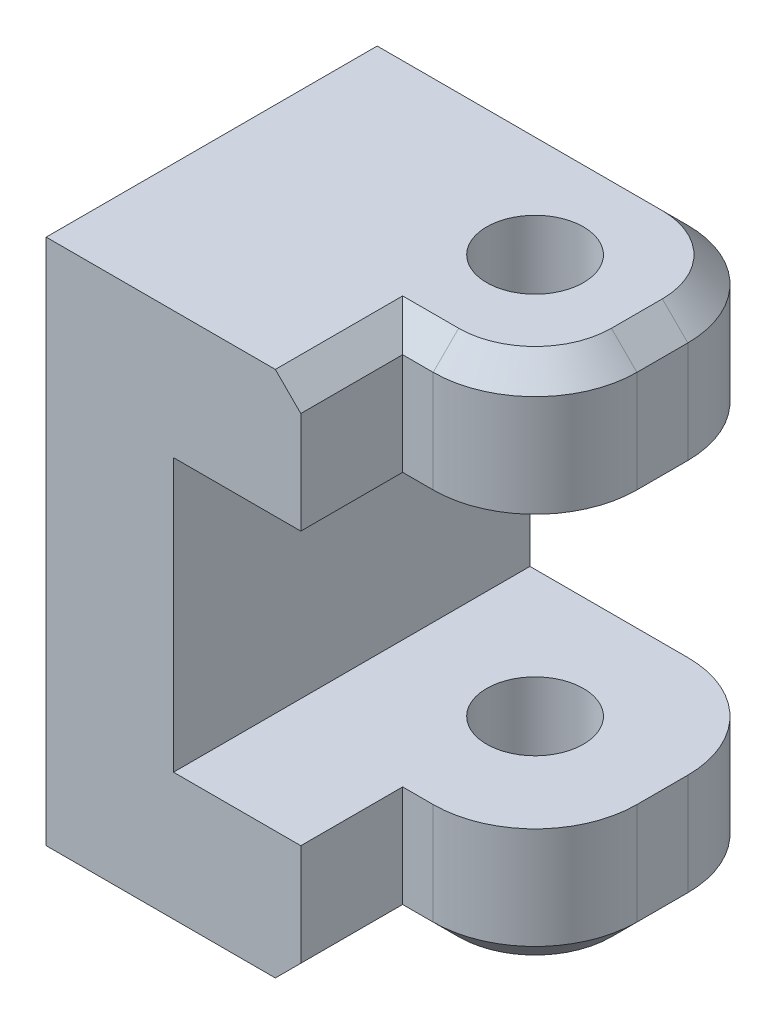
from build123d import *

# Parameters (mm, degrees)
SKETCH_1_R               = 6.25
EXTRUDE_1_DEPTH          = 15
SKETCH_2_W               = 29.5
SKETCH_2_H               = 20.7
EXTRUDE_2_DEPTH          = 5
SKETCH_3_W               = 39
SKETCH_3_H               = 20.7
SKETCH_3_R               = 1.6
EXTRUDE_3_DEPTH          = 5
SKETCH_4_W               = 10
SKETCH_4_H               = 5
EXTRUDE_4_DEPTH          = 10.2
SKETCH_5_R               = 1.9
CUT_EXTRUDE_1_DEPTH      = 21.7
FILLET_1_R               = 4
SKETCH_8_W               = 24
SKETCH_8_H               = 5
EXTRUDE_6_DEPTH          = 5
SKETCH_9_R               = 1.6
EXTRUDE_7_DEPTH          = 5
EXTRUDE_5_DEPTH          = 3
CHAMFER_1_SIZE           = 1
CHAMFER_2_SIZE           = 1
SKETCH_10_W              = 6.3
SKETCH_10_H              = 5.8
CUT_EXTRUDE_2_DEPTH      = 2.5
SKETCH_11_R              = 1.65
CUT_EXTRUDE_3_DEPTH      = 25.95
CUT_EXTRUDE_3_DEPTH_BACK = 15.75
CUT_EXTRUDE_4_DEPTH      = 1
CUT_EXTRUDE_4_DEPTH_BACK = 21.7


with BuildPart() as part:
    # ｽｹｯﾁ1 → ﾎﾞｽ - 押し出し1 (new body)
    with BuildSketch(Plane.XY):
        Circle(SKETCH_1_R)
    extrude(amount=-EXTRUDE_1_DEPTH)

    # ｽｹｯﾁ2 → ﾎﾞｽ - 押し出し2 (add)
    with BuildSketch(Plane.XY):
        Rectangle(SKETCH_2_W, SKETCH_2_H)
    extrude(amount=EXTRUDE_2_DEPTH)

    # ｽｹｯﾁ3 → ﾎﾞｽ - 押し出し3 (add)
    with BuildSketch(Plane(origin=(14.75, 0, 0), x_dir=(0, 0, -1), z_dir=(1, 0, 0))):
        with Locations((-24.5, 0)):
            Rectangle(SKETCH_3_W, SKETCH_3_H)
        with Locations((-20, 0)):
            Circle(SKETCH_3_R, mode=Mode.SUBTRACT)
    extrude(amount=-EXTRUDE_3_DEPTH)

    # ｽｹｯﾁ4 → ﾎﾞｽ - 押し出し4 (add)
    with BuildSketch(Plane(origin=(14.75, 0, 0), x_dir=(0, 0, -1), z_dir=(1, 0, 0))):
        with Locations((-5, 7.85)):
            Rectangle(SKETCH_4_W, SKETCH_4_H)
        with Locations((-5, -7.85)):
            Rectangle(SKETCH_4_W, SKETCH_4_H)
        with Locations((-39, 7.85)):
            Rectangle(SKETCH_4_W, SKETCH_4_H)
        with Locations((-39, -7.85)):
            Rectangle(SKETCH_4_W, SKETCH_4_H)
    extrude(amount=EXTRUDE_4_DEPTH)

    # ｽｹｯﾁ5 → ｶｯﾄ - 押し出し1 (cut, through all)
    with BuildSketch(Plane.XZ.offset(10.35)):
        with Locations((19.95, 5)):
            Circle(SKETCH_5_R)
        with Locations((19.95, 39)):
            Circle(SKETCH_5_R)
    extrude(amount=-CUT_EXTRUDE_1_DEPTH, mode=Mode.SUBTRACT)

    # ﾌｨﾚｯﾄ1
    fillet_1_edges = [part.edges().sort_by_distance(p)[0] for p in [
        (24.95, 7.85, 0),
        (24.95, 7.85, 10),
        (24.95, -7.85, 0),
        (24.95, -7.85, 10),
        (24.95, -7.85, 44),
        (24.95, -7.85, 34),
        (24.95, 7.85, 44),
        (24.95, 7.85, 34),
    ]]
    fillet(fillet_1_edges, radius=FILLET_1_R)

    # ｽｹｯﾁ8 → ﾎﾞｽ - 押し出し6 (add)
    with BuildSketch(Plane(origin=(14.75, 0, 0), x_dir=(0, 0, -1), z_dir=(1, 0, 0))):
        with Locations((-22, 7.85)):
            Rectangle(SKETCH_8_W, SKETCH_8_H)
        with Locations((-22, -7.85)):
            Rectangle(SKETCH_8_W, SKETCH_8_H)
    extrude(amount=EXTRUDE_6_DEPTH)

    # ｽｹｯﾁ9 → ﾎﾞｽ - 押し出し7 (add)
    with BuildSketch(Plane.ZY.offset(14.75)):
        with BuildLine():
            Line((5, 10.35), (11, 10.35))
            Line((11, 10.35), (22.121751649, 3.390895153))
            ThreePointArc((22.121751649, 3.390895153), (24, 0), (22.121751649, -3.390895153))
            Line((22.121751649, -3.390895153), (11, -10.35))
            Line((11, -10.35), (5, -10.35))
            Line((5, -10.35), (5, 10.35))
        make_face()
        with Locations((20, 0)):
            Circle(SKETCH_9_R, mode=Mode.SUBTRACT)
    extrude(amount=-EXTRUDE_7_DEPTH)

    # ｽｹｯﾁ6 → ﾎﾞｽ - 押し出し5 (add)
    with BuildSketch(Plane.XZ.offset(10.35)):
        Polygon((-9.75, 5), (9.75, 5), (9.75, 15), (-2.374355653, 8), (-9.75, 8), align=None)
    extrude_5 = extrude(amount=-EXTRUDE_5_DEPTH)

    # ﾐﾗｰ1: ﾎﾞｽ - 押し出し5 across plane
    add(extrude_5.mirror(Plane.ZX))

    # 面取り1
    chamfer_1_edges = [part.edges().sort_by_distance(p)[0] for p in [
        (20.35, -10.35, 34),
        (24.95, -10.35, 5),
        (20.35, -10.35, 10),
        (23.778427125, -10.35, 8.828427125),
        (23.778427125, -10.35, 1.171572875),
        (23.778427125, -10.35, 42.828427125),
        (23.778427125, -10.35, 35.171572875),
        (24.95, 10.35, 39),
        (3.1, 10.35, 0),
        (20.35, 10.35, 34),
        (20.35, 10.35, 10),
        (24.95, 10.35, 5),
        (23.778427125, 10.35, 1.171572875),
        (23.778427125, 10.35, 8.828427125),
        (23.778427125, 10.35, 42.828427125),
        (23.778427125, 10.35, 35.171572875),
        (19.75, 10.35, 22),
        (19.75, -10.35, 22),
        (9.75, -10.35, 29.5),
        (9.75, 0, 44),
        (15.35, -10.35, 44),
        (15.35, 10.35, 44),
        (9.75, 10.35, 29.5),
        (-14.75, 0, 0),
        (-14.75, 10.35, 5.5),
        (3.1, -10.35, 0),
        (-14.75, -10.35, 5.5),
        (24.95, -10.35, 39),
    ]]
    chamfer(chamfer_1_edges, length=CHAMFER_1_SIZE)

    # 面取り2
    chamfer_2_edges = [part.edges().sort_by_distance(p)[0] for p in [
        (-9.75, -8.85, 8),
        (-9.75, 8.85, 8),
    ]]
    chamfer(chamfer_2_edges, length=CHAMFER_2_SIZE)

    # ｽｹｯﾁ10 → ｶｯﾄ - 押し出し2 (cut)
    with BuildSketch(Plane(origin=(14.75, 0, 0), x_dir=(0, 0, -1), z_dir=(1, 0, 0))):
        with Locations((-20, 0)):
            Rectangle(SKETCH_10_W, SKETCH_10_H)
    extrude(amount=-CUT_EXTRUDE_2_DEPTH, mode=Mode.SUBTRACT)

    # ｽｹｯﾁ11 → ｶｯﾄ - 押し出し3 (cut, two sides)
    with BuildSketch(Plane(origin=(0, 0, 0), x_dir=(0, 0, -1), z_dir=(1, 0, 0))) as cut_extrude_3_sk:
        with Locations((7.5, 0)):
            Circle(SKETCH_11_R)
    extrude(amount=CUT_EXTRUDE_3_DEPTH, mode=Mode.SUBTRACT)
    extrude(cut_extrude_3_sk.sketch, amount=-CUT_EXTRUDE_3_DEPTH_BACK, mode=Mode.SUBTRACT)

    # ｽｹｯﾁ12 → ｶｯﾄ - 押し出し4 (cut, two sides)
    with BuildSketch(Plane(origin=(0, 10.35, 0), x_dir=(1, 0, 0), z_dir=(0, 1, 0))) as cut_extrude_4_sk:
        Polygon((147.57222826, -14), (29.932862948, -14), (9.75, -14), (9.75, 2.815371833), (9.75, 120.454737145), (-154.547009772, -47.957179489), (-16.724781512, -182.411916634), align=None)
    extrude(amount=CUT_EXTRUDE_4_DEPTH, mode=Mode.SUBTRACT)
    extrude(cut_extrude_4_sk.sketch, amount=-CUT_EXTRUDE_4_DEPTH_BACK, mode=Mode.SUBTRACT)


solid = part.part
